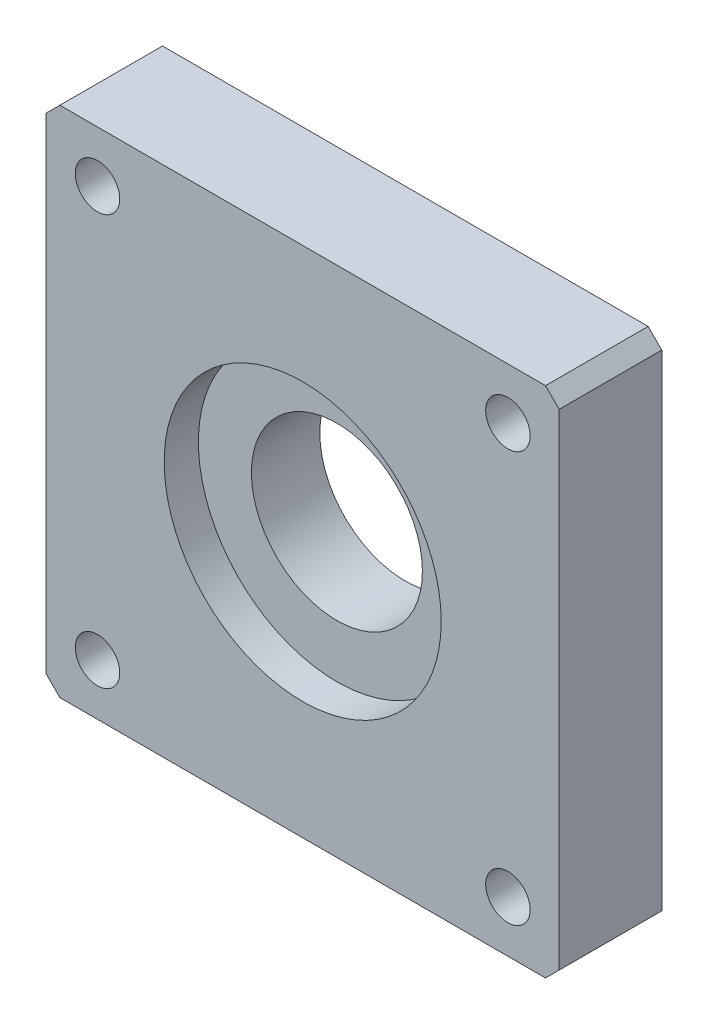
from build123d import *

# Parameters (mm, degrees)
SKETCH_1_W          = 75
SKETCH_1_H          = 75
EXTRUDE_1_DEPTH     = 15
CHAMFER_1_SIZE      = 2
SKETCH_2_R          = 12.5
SKETCH_2_R_2        = 3.25
CUT_EXTRUDE_1_DEPTH = 16
SKETCH_3_R          = 20.25
CUT_EXTRUDE_2_DEPTH = 5


with BuildPart() as part:
    # 草图1 → 凸台-拉伸1 (new body)
    with BuildSketch(Plane.XY):
        with Locations((37.5, -37.5)):
            Rectangle(SKETCH_1_W, SKETCH_1_H)
    extrude(amount=EXTRUDE_1_DEPTH)

    # 倒角1
    chamfer_1_edges = [part.edges().sort_by_distance(p)[0] for p in [
        (0, 0, 7.5),
        (75, 0, 7.5),
        (75, -75, 7.5),
        (0, -75, 7.5),
    ]]
    chamfer(chamfer_1_edges, length=CHAMFER_1_SIZE)

    # 草图2 → 切除-拉伸1 (cut, through all)
    with BuildSketch(Plane.XY.offset(15)):
        with Locations((37.5, -37.5)):
            Circle(SKETCH_2_R)
        with Locations((7.5, -7.5)):
            Circle(SKETCH_2_R_2)
        with Locations((67.5, -7.5)):
            Circle(SKETCH_2_R_2)
        with Locations((67.5, -67.5)):
            Circle(SKETCH_2_R_2)
        with Locations((7.5, -67.5)):
            Circle(SKETCH_2_R_2)
    extrude(amount=-CUT_EXTRUDE_1_DEPTH, mode=Mode.SUBTRACT)

    # 草图3 → 切除-拉伸2 (cut)
    with BuildSketch(Plane.XY.offset(15)):
        with Locations((37.5, -37.5)):
            Circle(SKETCH_3_R)
    extrude(amount=-CUT_EXTRUDE_2_DEPTH, mode=Mode.SUBTRACT)


solid = part.part
